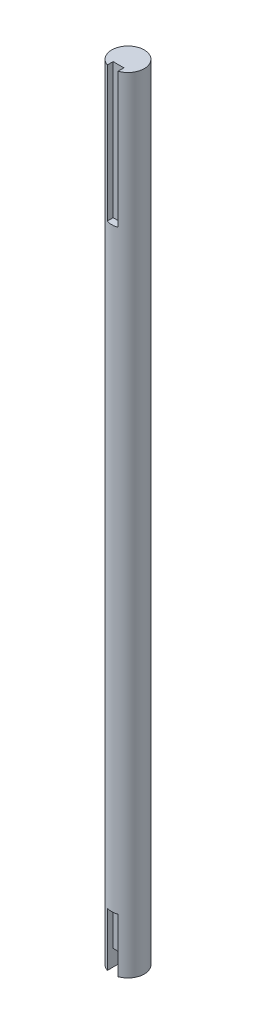
from build123d import *

# Parameters (mm, degrees)
SKETCH1_R                = 6
BOSS_EXTRUDE1_DEPTH      = 254
BOSS_EXTRUDE1_DEPTH_BACK = 36
CUT_EXTRUDE3_START       = -36
SKETCH2_W                = 4
SKETCH2_H                = 5
CUT_EXTRUDE3_DEPTH       = 20
CUT_EXTRUDE3_DEPTH_BACK  = 0.0001
CUT_EXTRUDE4_START       = 254
SKETCH2_2_W              = 4
SKETCH2_2_H              = 5
CUT_EXTRUDE4_DEPTH       = 50
CUT_EXTRUDE6_START       = -36
SKETCH3_W                = 4
SKETCH3_H                = 10
CUT_EXTRUDE6_DEPTH       = 6


with BuildPart() as part:
    # Sketch1 → Boss-Extrude1 (new body, two sides)
    with BuildSketch(Plane(origin=(0, 0, 0), x_dir=(1, 0, 0), z_dir=(0, 1, 0))) as boss_extrude1_sk:
        Circle(SKETCH1_R)
    extrude(amount=BOSS_EXTRUDE1_DEPTH)
    extrude(boss_extrude1_sk.sketch, amount=-BOSS_EXTRUDE1_DEPTH_BACK)

    # Sketch2 → Cut-Extrude3 (cut, two sides)
    with BuildSketch(Plane(origin=(0, 0, 0), x_dir=(1, 0, 0), z_dir=(0, 1, 0)).offset(CUT_EXTRUDE3_START)) as cut_extrude3_sk:
        with Locations((0, -6)):
            Rectangle(SKETCH2_W, SKETCH2_H)
    extrude(amount=CUT_EXTRUDE3_DEPTH, mode=Mode.SUBTRACT)
    extrude(cut_extrude3_sk.sketch, amount=-CUT_EXTRUDE3_DEPTH_BACK, mode=Mode.SUBTRACT)

    # Sketch2_2 → Cut-Extrude4 (cut)
    with BuildSketch(Plane(origin=(0, 0, 0), x_dir=(1, 0, 0), z_dir=(0, 1, 0)).offset(CUT_EXTRUDE4_START)):
        with Locations((0, -6)):
            Rectangle(SKETCH2_2_W, SKETCH2_2_H)
    extrude(amount=-CUT_EXTRUDE4_DEPTH, mode=Mode.SUBTRACT)

    # Sketch3 → Cut-Extrude6 (cut)
    with BuildSketch(Plane(origin=(0, 0, 0), x_dir=(1, 0, 0), z_dir=(0, 1, 0)).offset(CUT_EXTRUDE6_START)):
        with Locations((0, -6)):
            Rectangle(SKETCH3_W, SKETCH3_H)
    extrude(amount=CUT_EXTRUDE6_DEPTH, mode=Mode.SUBTRACT)


solid = part.part
